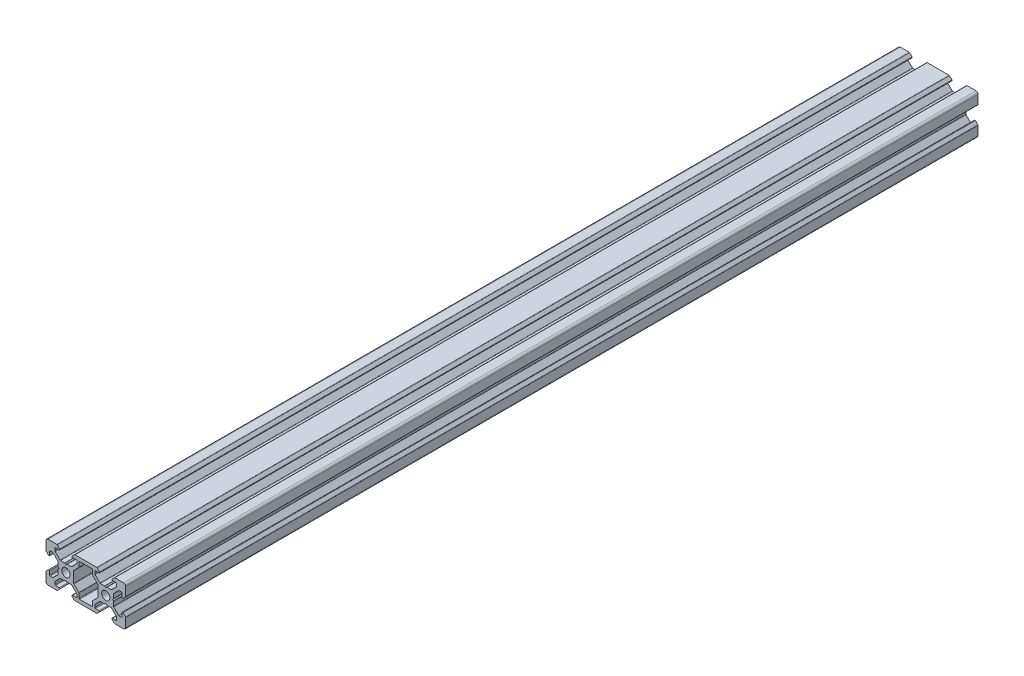
from build123d import *

# Parameters (mm, degrees)
SKETCH_1_R      = 2.1
EXTRUDE_1_DEPTH = 428
FILLET_1_R      = 1
FILLET_2_R      = 0.3


with BuildPart() as part:
    # Эскиз1 → Бобышка-Вытянуть1 (new body)
    with BuildSketch(Plane.XY):
        Polygon((-10, -10), (-10, -4.4), (-8.2, -2.6), (-8.2, -5.499339828), (-6.56, -5.499339828), (-3.900660172, -2.84), (-3.900660172, -0.5), (-3.400660172, 0), (-3.900660172, 0.5), (-3.900660172, 2.84), (-6.56, 5.499339828), (-8.2, 5.499339828), (-8.2, 2.6), (-10, 4.4), (-10, 10), (-4.4, 10), (-2.6, 8.2), (-5.499339828, 8.2), (-5.499339828, 6.56), (-2.84, 3.900660172), (-0.5, 3.900660172), (0, 3.400660172), (0.5, 3.900660172), (2.84, 3.900660172), (5.499339828, 6.56), (5.499339828, 8.2), (2.6, 8.2), (4.4, 10), (15.6, 10), (17.4, 8.2), (14.500660172, 8.2), (14.500660172, 6.56), (17.16, 3.900660172), (19.5, 3.900660172), (20, 3.400660172), (20.5, 3.900660172), (22.84, 3.900660172), (25.499339828, 6.56), (25.499339828, 8.2), (22.6, 8.2), (24.4, 10), (30, 10), (30, 4.4), (28.2, 2.6), (28.2, 5.499339828), (26.56, 5.499339828), (23.900660172, 2.84), (23.900660172, 0.5), (23.400660172, 0), (23.900660172, -0.5), (23.900660172, -2.84), (26.56, -5.499339828), (28.2, -5.499339828), (28.2, -2.6), (30, -4.4), (30, -10), (24.4, -10), (22.6, -8.2), (25.499339828, -8.2), (25.499339828, -6.56), (22.84, -3.900660172), (20.5, -3.900660172), (20, -3.400660172), (19.5, -3.900660172), (17.16, -3.900660172), (14.500660172, -6.56), (14.500660172, -8.2), (17.4, -8.2), (15.6, -10), (4.4, -10), (2.6, -8.2), (5.499339828, -8.2), (5.499339828, -6.56), (2.84, -3.900660172), (0.5, -3.900660172), (0, -3.400660172), (-0.5, -3.900660172), (-2.84, -3.900660172), (-5.499339828, -6.56), (-5.499339828, -8.2), (-2.6, -8.2), (-4.4, -10), align=None)
        Circle(SKETCH_1_R, mode=Mode.SUBTRACT)
        with Locations((20, 0)):
            Circle(SKETCH_1_R, mode=Mode.SUBTRACT)
        Polygon((3.900660172, -0.5), (3.900660172, 0.5), (3.900660172, 2.84), (6.56, 5.499339828), (6.56, 8.2), (13.44, 8.2), (13.44, 5.499339828), (16.099339828, 2.84), (16.099339828, 0.5), (16.099339828, -0.5), (16.099339828, -2.84), (13.44, -5.499339828), (13.44, -8.2), (6.56, -8.2), (6.56, -5.499339828), (3.900660172, -2.84), align=None, mode=Mode.SUBTRACT)
    extrude(amount=EXTRUDE_1_DEPTH)

    # Скругление1
    fillet_1_edges = [part.edges().sort_by_distance(p)[0] for p in [
        (-10, -10, 214),
        (-10, 10, 214),
        (30, 10, 214),
        (30, -10, 214),
    ]]
    fillet(fillet_1_edges, radius=FILLET_1_R)

    # Скругление2
    fillet_2_edges = [part.edges().sort_by_distance(p)[0] for p in [
        (6.56, -5.499339828, 214),
        (6.56, -8.2, 214),
        (3.900660172, -2.84, 214),
        (3.900660172, 2.84, 214),
        (6.56, 5.499339828, 214),
        (6.56, 8.2, 214),
        (13.44, 8.2, 214),
        (13.44, 5.499339828, 214),
        (16.099339828, 2.84, 214),
        (16.099339828, -2.84, 214),
        (13.44, -5.499339828, 214),
        (13.44, -8.2, 214),
        (-10, -4.4, 214),
        (-8.2, -2.6, 214),
        (-8.2, -5.499339828, 214),
        (-6.56, -5.499339828, 214),
        (-3.900660172, -2.84, 214),
        (-3.900660172, -0.5, 214),
        (-3.900660172, 0.5, 214),
        (-3.900660172, 2.84, 214),
        (-6.56, 5.499339828, 214),
        (-8.2, 5.499339828, 214),
        (-8.2, 2.6, 214),
        (-10, 4.4, 214),
        (-4.4, 10, 214),
        (-2.6, 8.2, 214),
        (-5.499339828, 8.2, 214),
        (-5.499339828, 6.56, 214),
        (-2.84, 3.900660172, 214),
        (-0.5, 3.900660172, 214),
        (0.5, 3.900660172, 214),
        (2.84, 3.900660172, 214),
        (5.499339828, 6.56, 214),
        (5.499339828, 8.2, 214),
        (2.6, 8.2, 214),
        (4.4, 10, 214),
        (15.6, 10, 214),
        (17.4, 8.2, 214),
        (14.500660172, 8.2, 214),
        (14.500660172, 6.56, 214),
        (17.16, 3.900660172, 214),
        (19.5, 3.900660172, 214),
        (20.5, 3.900660172, 214),
        (22.84, 3.900660172, 214),
        (25.499339828, 6.56, 214),
        (25.499339828, 8.2, 214),
        (22.6, 8.2, 214),
        (24.4, 10, 214),
        (30, 4.4, 214),
        (28.2, 2.6, 214),
        (28.2, 5.499339828, 214),
        (26.56, 5.499339828, 214),
        (23.900660172, 2.84, 214),
        (23.900660172, 0.5, 214),
        (23.900660172, -0.5, 214),
        (23.900660172, -2.84, 214),
        (26.56, -5.499339828, 214),
        (28.2, -5.499339828, 214),
        (28.2, -2.6, 214),
        (30, -4.4, 214),
        (24.4, -10, 214),
        (22.6, -8.2, 214),
        (25.499339828, -8.2, 214),
        (25.499339828, -6.56, 214),
        (22.84, -3.900660172, 214),
        (20.5, -3.900660172, 214),
        (19.5, -3.900660172, 214),
        (17.16, -3.900660172, 214),
        (14.500660172, -6.56, 214),
        (14.500660172, -8.2, 214),
        (17.4, -8.2, 214),
        (15.6, -10, 214),
        (4.4, -10, 214),
        (2.6, -8.2, 214),
        (5.499339828, -8.2, 214),
        (5.499339828, -6.56, 214),
        (2.84, -3.900660172, 214),
        (0.5, -3.900660172, 214),
        (-0.5, -3.900660172, 214),
        (-2.84, -3.900660172, 214),
        (-5.499339828, -6.56, 214),
        (-5.499339828, -8.2, 214),
        (-2.6, -8.2, 214),
    ]]
    fillet(fillet_2_edges, radius=FILLET_2_R)


solid = part.part
